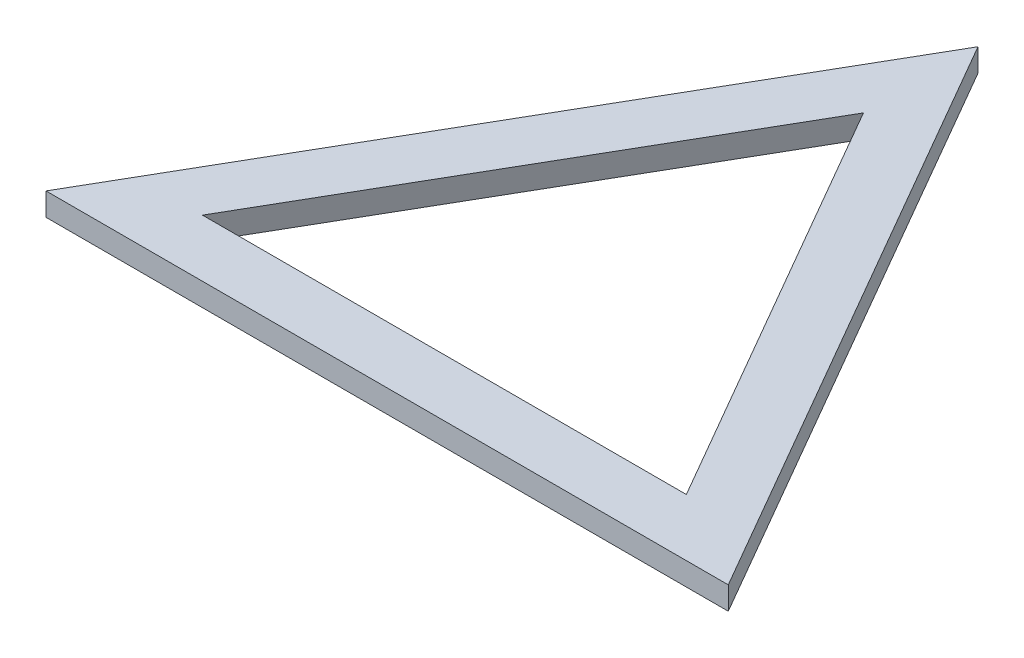
from build123d import *

# Parameters (mm, degrees)
BOSS_EXTRUDE1_DEPTH = 2


with BuildPart() as part:
    # Sketch1 → Boss-Extrude1 (new body)
    with BuildSketch(Plane(origin=(0, 0, 0), x_dir=(1, 0, 0), z_dir=(0, 1, 0))):
        Polygon((0, 0), (29.8074, 51.627931242), (59.6148, 0), align=None)
        Polygon((50.9474, 5.004125723), (8.6674, 5.004125723), (29.8074, 41.619679795), align=None, mode=Mode.SUBTRACT)
    extrude(amount=BOSS_EXTRUDE1_DEPTH)


solid = part.part
